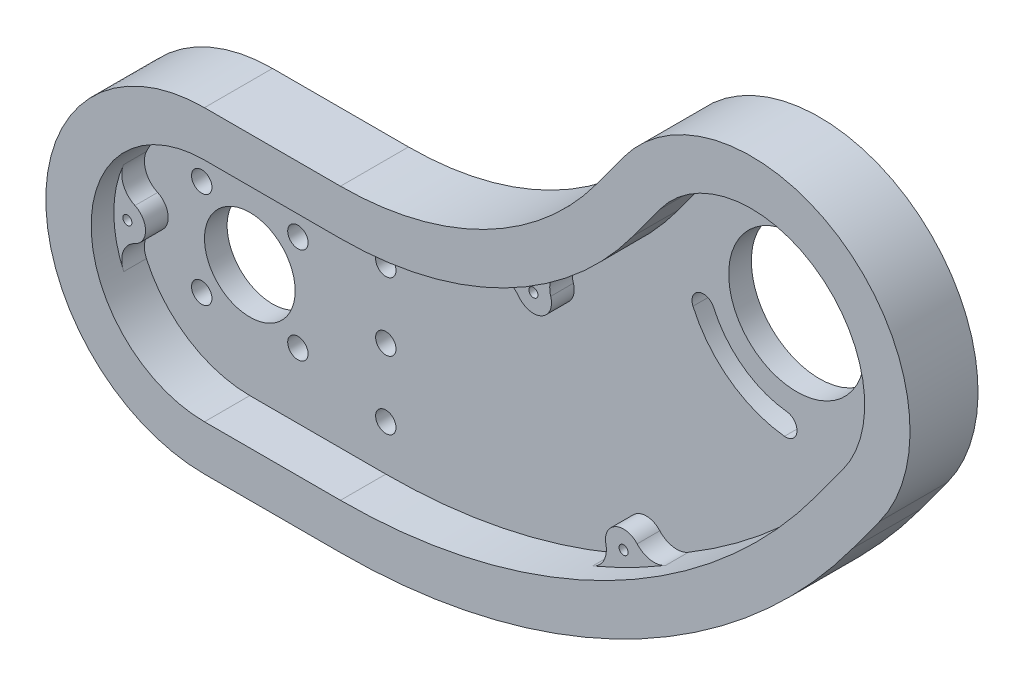
from build123d import *

# Parameters (mm, degrees)
EXTRUDE_1_DEPTH                 = 20
CHAMFER_1_SIZE                  = 10
CUT_EXTRUDE_1_DEPTH             = 15
SKETCH_3_R                      = 15
CUT_EXTRUDE_2_DEPTH             = 20
SKETCH_4_R                      = 2.25
SKETCH_4_R_2                    = 10
CUT_EXTRUDE_3_DEPTH             = 20
SKETCH_5_R                      = 4
EXTRUDE_3_DEPTH                 = 5
FILLET_1_R                      = 5
SKETCH_6_R                      = 1
CUT_EXTRUDE_4_DEPTH             = 10
FILLET_2_R                      = 5
CUT_EXTRUDE_5_REACH             = 22
CUT_EXTRUDE_5_DIRECTION_2_DEPTH = 1.0000001
EXTRUDE_4_DEPTH                 = 13
CUT_EXTRUDE_6_DEPTH             = 5


with BuildPart() as part:
    # 스케치1 → 보스-돌출1 (new body)
    with BuildSketch(Plane.XY):
        with BuildLine():
            Line((0, 35), (30, 35))
            ThreePointArc((30, 35), (61.66442854, 42.571128753), (86.479272356, 63.646743851))
            Line((86.479272356, 63.646743851), (92.386880378, 71.715211331))
            ThreePointArc((92.386880378, 71.715211331), (141.30314463, 79.278219435), (148.866152734, 30.361955182))
            Line((148.866152734, 30.361955182), (142.958544713, 22.293487703))
            ThreePointArc((142.958544713, 22.293487703), (93.328857081, -19.857742494), (30, -35))
            Line((30, -35), (0, -35))
            ThreePointArc((0, -35), (-35, 0), (0, 35))
        make_face()
    extrude(amount=EXTRUDE_1_DEPTH)

    # 모따기1
    chamfer_1_edges = [part.edges().sort_by_distance(p)[0] for p in [
        (141.30314463, 79.278219435, 20),
        (89.433076367, 67.680977591, 20),
        (61.66442854, 42.571128753, 20),
        (15, 35, 20),
        (-35, 0, 20),
        (15, -35, 20),
        (93.328857081, -19.857742494, 20),
        (145.912348723, 26.327721442, 20),
    ]]
    chamfer(chamfer_1_edges, length=CHAMFER_1_SIZE)

    # 스케치2 → 컷-돌출1 (cut)
    with BuildSketch(Plane.XY.offset(20)):
        with BuildLine():
            Line((30, 25), (0, 25))
            ThreePointArc((0, 25), (-25, 0), (0, -25))
            Line((0, -25), (30, -25))
            ThreePointArc((30, -25), (88.805367289, -10.939332316), (134.890077233, 28.201095724))
            Line((134.890077233, 28.201095724), (140.797685254, 36.269563203))
            ThreePointArc((140.797685254, 36.269563203), (135.395536609, 71.209751955), (100.455347857, 65.80760331))
            Line((100.455347857, 65.80760331), (94.547739836, 57.73913583))
            ThreePointArc((94.547739836, 57.73913583), (66.187918332, 33.652718575), (30, 25))
        make_face()
    extrude(amount=-CUT_EXTRUDE_1_DEPTH, mode=Mode.SUBTRACT)

    # 스케치3 → 컷-돌출2 (cut)
    with BuildSketch(Plane.XY.offset(5)):
        with Locations((120.626516556, 51.038583256)):
            Circle(SKETCH_3_R)
    extrude(amount=-CUT_EXTRUDE_2_DEPTH, mode=Mode.SUBTRACT)

    # 스케치4 → 컷-돌출3 (cut)
    with BuildSketch(Plane.XY.offset(5)):
        with Locations((10.606601718, 10.606601718)):
            Circle(SKETCH_4_R)
        with Locations((10.606601718, -10.606601718)):
            Circle(SKETCH_4_R)
        with Locations((-10.606601718, -10.606601718)):
            Circle(SKETCH_4_R)
        with Locations((-10.606601718, 10.606601718)):
            Circle(SKETCH_4_R)
        with Locations((30, 0)):
            Circle(SKETCH_4_R)
        with Locations((30, 15)):
            Circle(SKETCH_4_R)
        with Locations((30, -15)):
            Circle(SKETCH_4_R)
        Circle(SKETCH_4_R_2)
    extrude(amount=-CUT_EXTRUDE_3_DEPTH, mode=Mode.SUBTRACT)

    # 스케치5 → 보스-돌출3 (add)
    with BuildSketch(Plane.XY.offset(5)):
        with Locations((-22, 0)):
            Circle(SKETCH_5_R)
        with Locations((133.623254202, 68.789211711)):
            Circle(SKETCH_5_R)
        with Locations((67.544965269, 30.977195521)):
            Circle(SKETCH_5_R)
        with Locations((87.448320352, -8.263809263)):
            Circle(SKETCH_5_R)
    extrude(amount=EXTRUDE_3_DEPTH)

    # 필렛1
    fillet_1_edges = [part.edges().sort_by_distance(p)[0] for p in [
        (-24.840909091, -2.81588983, 7.5),
        (-24.840909091, 2.81588983, 7.5),
        (133.029560383, 72.744907307, 7.5),
        (137.573543488, 69.417872638, 7.5),
        (68.485091989, 34.865146363, 7.5),
        (63.852594761, 32.515506293, 7.5),
        (91.180070497, -9.703962329, 7.5),
        (86.405731461, -12.125545712, 7.5),
    ]]
    fillet(fillet_1_edges, radius=FILLET_1_R)

    # 스케치6 → 컷-돌출4 (cut)
    with BuildSketch(Plane.XY.offset(10)):
        with Locations((67.544965269, 30.977195521)):
            Circle(SKETCH_6_R)
        with Locations((87.448320352, -8.263809263)):
            Circle(SKETCH_6_R)
        with Locations((-22, 0)):
            Circle(SKETCH_6_R)
        with Locations((133.623254202, 68.789211711)):
            Circle(SKETCH_6_R)
    extrude(amount=-CUT_EXTRUDE_4_DEPTH, mode=Mode.SUBTRACT)

    # 필렛2
    fillet_2_edges = [part.edges().sort_by_distance(p)[0] for p in [
        (141.30314463, 79.278219435, 10),
        (89.433076367, 67.680977591, 10),
        (145.912348723, 26.327721442, 10),
        (61.66442854, 42.571128753, 10),
        (93.328857081, -19.857742494, 10),
        (15, 35, 10),
        (15, -35, 10),
        (-35, 0, 10),
    ]]
    fillet(fillet_2_edges, radius=FILLET_2_R)

    # 스케치7 → 컷-돌출5 (cut, up to next)
    with BuildSketch(Plane(origin=(0, 0, 0), x_dir=(-1, 0, 0), z_dir=(0, 0, -1)), mode=Mode.PRIVATE) as cut_extrude_5_sk1:
        with BuildLine():
            ThreePointArc((-117.92175435, 26.185328713), (-105.857496503, 30.867414558), (-97.750585651, 40.954348766))
            ThreePointArc((-97.750585651, 40.954348766), (-99.029755293, 44.250365305), (-102.325771832, 42.971195664))
            ThreePointArc((-102.325771832, 42.971195664), (-108.811300513, 34.901648297), (-118.462706791, 31.155979621))
            ThreePointArc((-118.462706791, 31.155979621), (-120.677556025, 28.400177947), (-117.92175435, 26.185328713))
        make_face()
    cut_extrude_5_tool1 = extrude(cut_extrude_5_sk1.sketch, amount=-CUT_EXTRUDE_5_REACH, mode=Mode.PRIVATE) & part.part
    add(cut_extrude_5_tool1.solids().sort_by_distance((108.102297, 33.933308, 0))[0], mode=Mode.SUBTRACT)

    # 스케치7 → 컷-돌출5 direction 2 (cut)
    with BuildSketch(Plane(origin=(0, 0, 0), x_dir=(-1, 0, 0), z_dir=(0, 0, -1))):
        with BuildLine():
            ThreePointArc((-117.92175435, 26.185328713), (-105.857496503, 30.867414558), (-97.750585651, 40.954348766))
            ThreePointArc((-97.750585651, 40.954348766), (-99.029755293, 44.250365305), (-102.325771832, 42.971195664))
            ThreePointArc((-102.325771832, 42.971195664), (-108.811300513, 34.901648297), (-118.462706791, 31.155979621))
            ThreePointArc((-118.462706791, 31.155979621), (-120.677556025, 28.400177947), (-117.92175435, 26.185328713))
        make_face()
    extrude(amount=CUT_EXTRUDE_5_DIRECTION_2_DEPTH, mode=Mode.SUBTRACT)

    # 스케치8 → 보스-돌출4 (add)
    with BuildSketch(Plane(origin=(0, 0, 20), x_dir=(-1, 0, 0), z_dir=(0, 0, -1))):
        with BuildLine():
            Line((-30, -35), (0, -35))
            ThreePointArc((0, -35), (35, 0), (0, 35))
            Line((0, 35), (-30, 35))
            ThreePointArc((-30, 35), (-61.66442854, 42.571128753), (-86.479272356, 63.646743851))
            Line((-86.479272356, 63.646743851), (-92.386880378, 71.715211331))
            ThreePointArc((-92.386880378, 71.715211331), (-141.30314463, 79.278219435), (-148.866152734, 30.361955182))
            Line((-148.866152734, 30.361955182), (-142.958544713, 22.293487703))
            ThreePointArc((-142.958544713, 22.293487703), (-93.328857081, -19.857742494), (-30, -35))
        make_face()
        with BuildLine():
            Line((-30, -25), (0, -25))
            ThreePointArc((0, -25), (25, 0), (0, 25))
            Line((0, 25), (-30, 25))
            ThreePointArc((-30, 25), (-66.187918332, 33.652718575), (-94.547739836, 57.73913583))
            Line((-94.547739836, 57.73913583), (-100.455347857, 65.80760331))
            ThreePointArc((-100.455347857, 65.80760331), (-135.395536609, 71.209751955), (-140.797685254, 36.269563203))
            Line((-140.797685254, 36.269563203), (-134.890077233, 28.201095724))
            ThreePointArc((-134.890077233, 28.201095724), (-88.805367289, -10.939332316), (-30, -25))
        make_face(mode=Mode.SUBTRACT)
    extrude(amount=EXTRUDE_4_DEPTH)

    # 스케치9 → 컷-돌출6 (cut)
    with BuildSketch(Plane.XY.offset(20)):
        with BuildLine():
            Line((0, -35), (30, -35))
            ThreePointArc((30, -35), (93.328857081, -19.857742494), (142.958544713, 22.293487703))
            Line((142.958544713, 22.293487703), (148.866152734, 30.361955182))
            ThreePointArc((148.866152734, 30.361955182), (141.30314463, 79.278219435), (92.386880378, 71.715211331))
            Line((92.386880378, 71.715211331), (86.479272356, 63.646743851))
            ThreePointArc((86.479272356, 63.646743851), (61.66442854, 42.571128753), (30, 35))
            Line((30, 35), (0, 35))
            ThreePointArc((0, 35), (-35, 0), (0, -35))
        make_face()
        with BuildLine():
            Line((0, -25), (30, -25))
            ThreePointArc((30, -25), (88.805367289, -10.939332316), (134.890077233, 28.201095724))
            Line((134.890077233, 28.201095724), (140.797685254, 36.269563203))
            ThreePointArc((140.797685254, 36.269563203), (135.395536609, 71.209751955), (100.455347857, 65.80760331))
            Line((100.455347857, 65.80760331), (94.547739836, 57.73913583))
            ThreePointArc((94.547739836, 57.73913583), (66.187918332, 33.652718575), (30, 25))
            Line((30, 25), (0, 25))
            ThreePointArc((0, 25), (-25, 0), (0, -25))
        make_face(mode=Mode.SUBTRACT)
    extrude(amount=-CUT_EXTRUDE_6_DEPTH, mode=Mode.SUBTRACT)


solid = part.part
